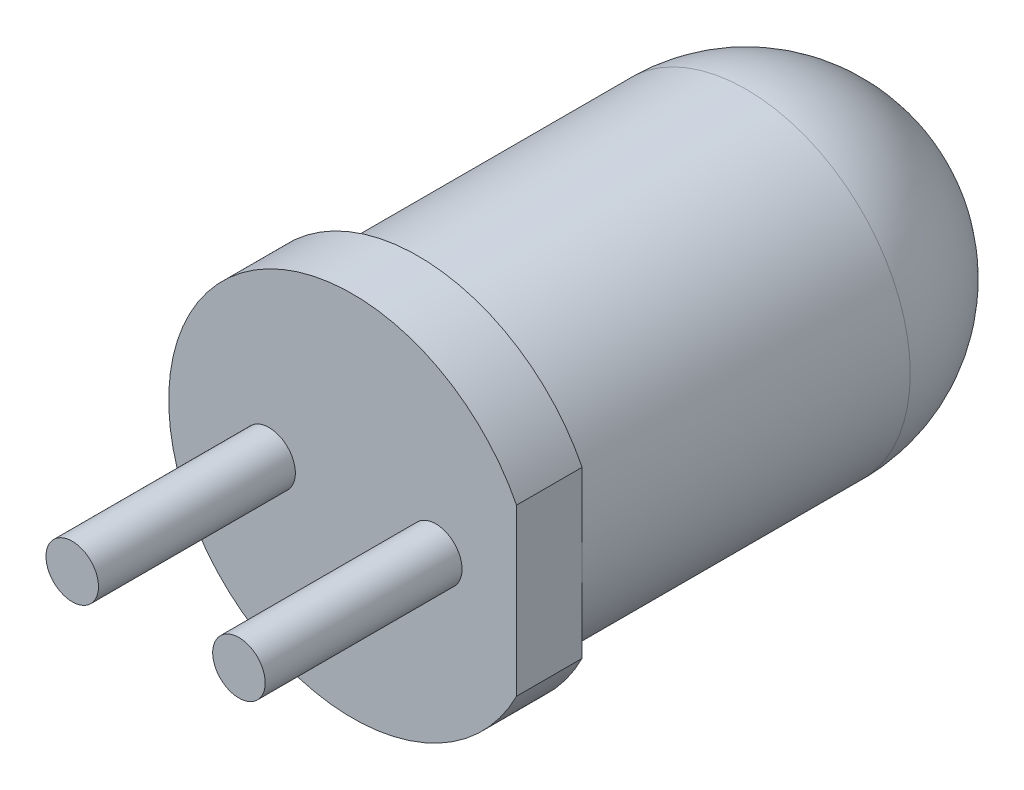
from build123d import *

# Parameters (mm, degrees)
ESQUISSE1_R          = 2.5
BASE_EXTRUSION_DEPTH = 8.5
BOSS_EXTRU_1_DEPTH   = 1
CONG_1_R             = 2.5
ESQUISSE3_R          = 0.4
EXTRUSION1_DEPTH     = 3


with BuildPart() as part:
    # Esquisse1 → Base-Extrusion (new body)
    with BuildSketch(Plane.XY):
        Circle(ESQUISSE1_R)
    extrude(amount=BASE_EXTRUSION_DEPTH)

    # Esquisse2 → Boss.-Extru.1 (add)
    with BuildSketch(Plane.XY.offset(8.5)):
        with BuildLine():
            Line((2.5, 1.260952021), (2.5, -1.260952021))
            ThreePointArc((2.5, -1.260952021), (-2.8, 0), (2.5, 1.260952021))
        make_face()
    extrude(amount=-BOSS_EXTRU_1_DEPTH)

    # Congé1
    cong_1_edges = [part.edges().sort_by_distance(p)[0] for p in [
        (-2.5, 0, 0),
    ]]
    fillet(cong_1_edges, radius=CONG_1_R)

    # Esquisse3 → Extrusion1 (add)
    with BuildSketch(Plane.XY.offset(8.5)):
        with Locations((1.27, 0)):
            Circle(ESQUISSE3_R)
        with Locations(Location((-1.27, 0, 0), (0, 0, 180))):  # turned: the seam where the file's is
            Circle(ESQUISSE3_R)
    extrude(amount=EXTRUSION1_DEPTH)


solid = part.part
